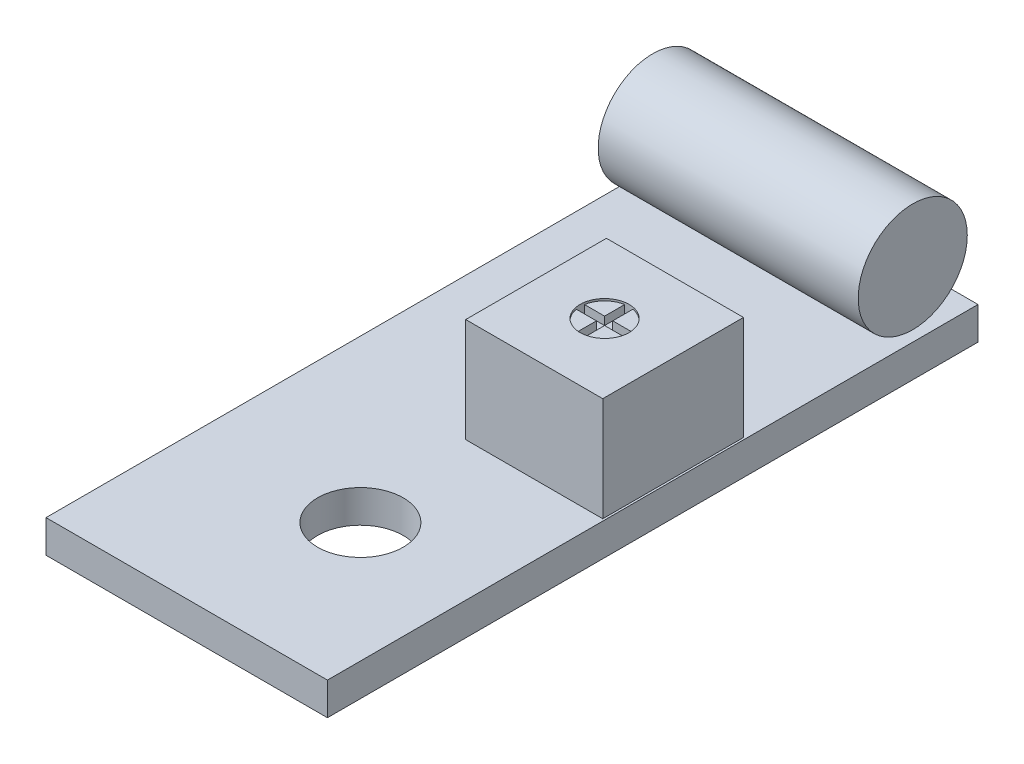
from build123d import *

# Parameters (mm, degrees)
SKETCH1_W                = 13.8
SKETCH1_H                = 31.9
BOSS_EXTRUDE1_DEPTH      = 1.6
SKETCH1_3_R              = 2.1
CUT_EXTRUDE2_DEPTH       = 18.878253538
BOSS_EXTRUDE2_DEPTH      = 6.7
BOSS_EXTRUDE3_DEPTH      = 6.375
BOSS_EXTRUDE3_DEPTH_BACK = 6.375
CUT_EXTRUDE7_DEPTH       = 0.1
CUT_EXTRUDE8_DEPTH       = 0.5


with BuildPart() as part:
    # Sketch1 → Boss-Extrude1 (new body)
    with BuildSketch(Plane(origin=(0, 0, 0), x_dir=(1, 0, 0), z_dir=(0, 1, 0))):
        with Locations((-1.016403829, 0)):
            Rectangle(SKETCH1_W, SKETCH1_H)
    extrude(amount=BOSS_EXTRUDE1_DEPTH)

    # Sketch1_3 → Cut-Extrude2 (cut, through all)
    with BuildSketch(Plane(origin=(0, 0, 0), x_dir=(1, 0, 0), z_dir=(0, 1, 0))):
        with Locations((0, -8.45)):
            Circle(SKETCH1_3_R)
    extrude(amount=CUT_EXTRUDE2_DEPTH, mode=Mode.SUBTRACT)

    # Sketch1_4 → Boss-Extrude2 (add)
    with BuildSketch(Plane(origin=(0, 0, 0), x_dir=(1, 0, 0), z_dir=(0, 1, 0))):
        Polygon((-0.936403829, 4.55), (-0.936403829, -2.35), (-0.836403829, -2.35), (5.783596171, -2.35), (5.783596171, 4.55), (-0.836403829, 4.55), align=None)
    extrude(amount=BOSS_EXTRUDE2_DEPTH)

    # Sketch5 → Cut-Extrude7 (cut)
    with BuildSketch(Plane(origin=(0, 6.7, 0), x_dir=(1, 0, 0), z_dir=(0, 1, 0))):
        with BuildLine():
            Line((1.240380214, 1.3), (2.223596171, 1.3))
            Line((2.223596171, 1.3), (2.223596171, 2.283215957))
            ThreePointArc((2.223596171, 2.283215957), (1.575068034, 1.948528137), (1.240380214, 1.3))
        make_face()
        with BuildLine():
            Line((2.223596171, 0.9), (1.240380214, 0.9))
            ThreePointArc((1.240380214, 0.9), (1.575068034, 0.251471863), (2.223596171, -0.083215957))
            Line((2.223596171, -0.083215957), (2.223596171, 0.9))
        make_face()
        with BuildLine():
            ThreePointArc((3.606812128, 1.3), (3.272124308, 1.948528137), (2.623596171, 2.283215957))
            Line((2.623596171, 2.283215957), (2.623596171, 1.3))
            Line((2.623596171, 1.3), (3.606812128, 1.3))
        make_face()
        with BuildLine():
            Line((2.623596171, 0.9), (2.623596171, -0.083215957))
            ThreePointArc((2.623596171, -0.083215957), (3.272124308, 0.251471863), (3.606812128, 0.9))
            Line((3.606812128, 0.9), (2.623596171, 0.9))
        make_face()
    extrude(amount=-CUT_EXTRUDE7_DEPTH, mode=Mode.SUBTRACT)

    # Sketch5_3 → Cut-Extrude8 (cut)
    with BuildSketch(Plane(origin=(0, 6.7, 0), x_dir=(1, 0, 0), z_dir=(0, 1, 0))):
        with BuildLine():
            Line((2.223596171, 2.283215957), (2.223596171, 1.3))
            Line((2.223596171, 1.3), (1.240380214, 1.3))
            ThreePointArc((1.240380214, 1.3), (1.223596171, 1.1), (1.240380214, 0.9))
            Line((1.240380214, 0.9), (2.223596171, 0.9))
            Line((2.223596171, 0.9), (2.223596171, -0.083215957))
            ThreePointArc((2.223596171, -0.083215957), (2.423596171, -0.1), (2.623596171, -0.083215957))
            Line((2.623596171, -0.083215957), (2.623596171, 0.9))
            Line((2.623596171, 0.9), (3.606812128, 0.9))
            ThreePointArc((3.606812128, 0.9), (3.619392798, 0.999648488), (3.623596171, 1.1))
            ThreePointArc((3.623596171, 1.1), (3.62109357, 1.177459529), (3.613596207, 1.254595974))
            Line((3.613596207, 1.254595974), (3.606812128, 1.3))
            Line((3.606812128, 1.3), (2.623596171, 1.3))
            Line((2.623596171, 1.3), (2.623596171, 2.283215957))
            ThreePointArc((2.623596171, 2.283215957), (2.423596171, 2.3), (2.223596171, 2.283215957))
        make_face()
    extrude(amount=-CUT_EXTRUDE8_DEPTH, mode=Mode.SUBTRACT)


with BuildPart() as body_2:
    # Sketch3 → Boss-Extrude3 (new, two sides: drawn at the far end of the back side and taken through both)
    with BuildSketch(Plane(origin=(-1.016403829, 0, 0), x_dir=(0, 0, -1), z_dir=(1, 0, 0)).offset(-BOSS_EXTRUDE3_DEPTH_BACK)):
        with BuildLine():
            ThreePointArc((13.275, 6.95), (11.38348936, 2.38348936), (15.95, 4.275))
            ThreePointArc((15.95, 4.275), (15.16651064, 6.16651064), (13.275, 6.95))
        make_face()
    extrude(amount=BOSS_EXTRUDE3_DEPTH + BOSS_EXTRUDE3_DEPTH_BACK)


solid = Compound([part.part, body_2.part])
